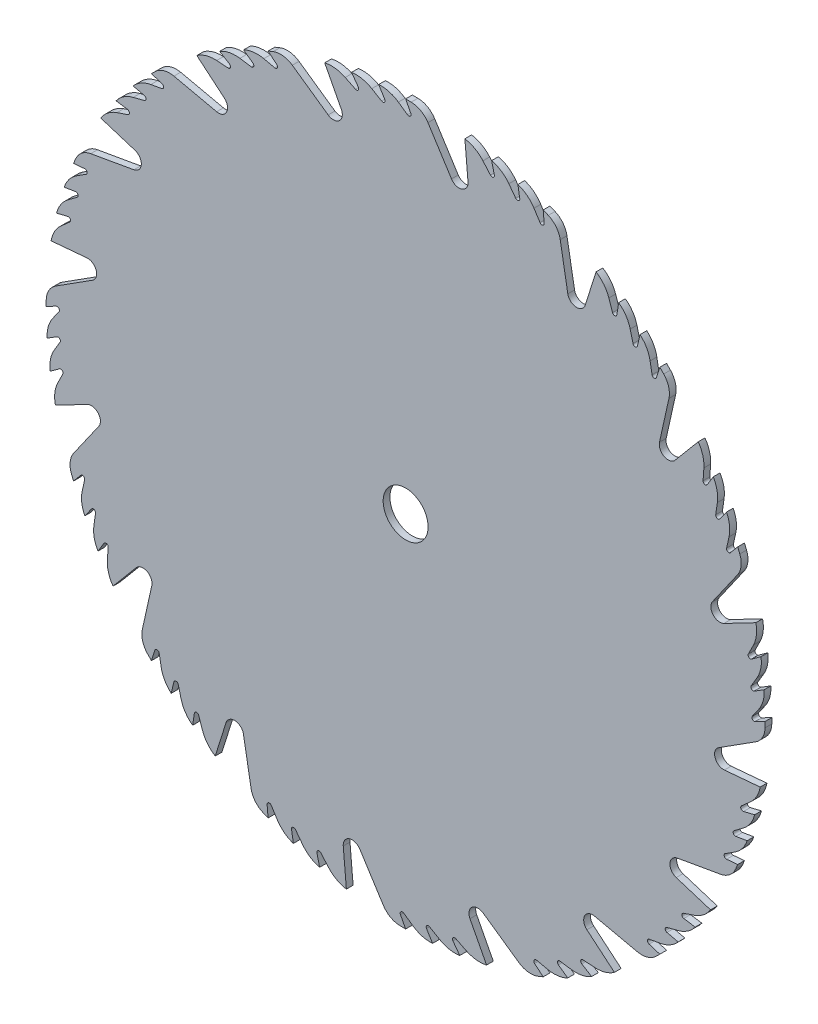
from build123d import *

# Parameters (mm, degrees)
SKETCH1_R         = 127
SKETCH1_R_2       = 7.9375
EXTRUDE1_DEPTH    = 2.38125
EXTRUDE2_DEPTH    = 3.38125
CIRPATTERN1_COUNT = 16


with BuildPart() as part:
    # Sketch1 → Extrude1 (new body)
    with BuildSketch(Plane.XY):
        Circle(SKETCH1_R)
        Circle(SKETCH1_R_2, mode=Mode.SUBTRACT)
    extrude(amount=EXTRUDE1_DEPTH)

    # Sketch2 → Extrude2 (cut, through all)
    with BuildSketch(Plane.XY.offset(2.38125)):
        with BuildLine():
            ThreePointArc((-28.595300987, 123.738873283), (-37.795178783, 121.24571935), (-46.78215889, 118.069596466))
            ThreePointArc((-46.78215889, 118.069596466), (-43.310236288, 118.52428233), (-40.037885926, 117.278204927))
            Line((-40.037885926, 117.278204927), (-27.36845818, 108.406976114))
            ThreePointArc((-27.36845818, 108.406976114), (-23.453930031, 108.620692466), (-22.731093599, 112.473835702))
            Line((-22.731093599, 112.473835702), (-28.595300987, 123.738873283))
        make_face()
        with BuildLine():
            Line((-16.717610416, 122.27189106), (-19.115355641, 125.553188644))
            ThreePointArc((-19.115355641, 125.553188644), (-23.872570536, 124.73612298), (-28.595300987, 123.738873283))
            ThreePointArc((-28.595300987, 123.738873283), (-24.896319978, 123.943955575), (-21.344297328, 122.891503985))
            Line((-21.344297328, 122.891503985), (-17.710713649, 121.092261016))
            ThreePointArc((-17.710713649, 121.092261016), (-16.751272258, 121.292379849), (-16.717610416, 122.27189106))
        make_face()
        with BuildLine():
            Line((-7.383377963, 123.18839057), (-9.525, 126.642308787))
            ThreePointArc((-9.525, 126.642308787), (-14.3305282, 126.188890008), (-19.115355641, 125.553188644))
            ThreePointArc((-19.115355641, 125.553188644), (-15.411482292, 125.476759145), (-11.949646433, 124.157588291))
            Line((-11.949646433, 124.157588291), (-8.463200246, 122.08758863))
            ThreePointArc((-8.463200246, 122.08758863), (-7.491331675, 122.21426464), (-7.383377963, 123.18839057))
        make_face()
        with BuildLine():
            Line((1.832564809, 123.479675756), (0, 127))
            ThreePointArc((0, 127), (-4.765856901, 126.910545693), (-9.525, 126.642308787))
            ThreePointArc((-9.525, 126.642308787), (-5.881323798, 126.289916856), (-2.568356114, 124.732739455))
            Line((-2.568356114, 124.732739455), (0.673223664, 122.462960859))
            ThreePointArc((0.673223664, 122.462960859), (1.651855701, 122.516389947), (1.832564809, 123.479675756))
        make_face()
    extrude2 = extrude(amount=-EXTRUDE2_DEPTH, mode=Mode.SUBTRACT)

    # CirPattern1: Extrude2 ×16 about axis
    cirpattern1_axis = Axis((0, 0, 0), (0, 0, 1))
    for i in range(1, CIRPATTERN1_COUNT):
        add(extrude2.rotate(cirpattern1_axis, i * 360 / CIRPATTERN1_COUNT), mode=Mode.SUBTRACT)


solid = part.part
